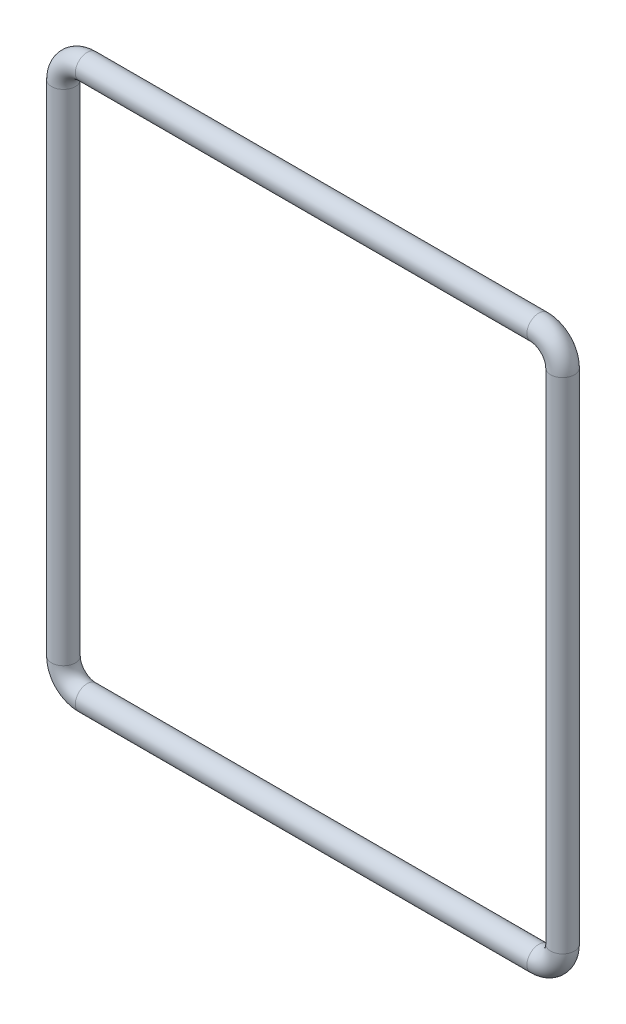
from build123d import *

# Parameters (mm, degrees)
ESQUISSE2_R = 1


with BuildPart() as part:
    # Balayage1: sweep along a path in Esquisse1
    with BuildLine(Plane.XY) as balayage1_path:
        Line((-19, 23), (19, 23))
        ThreePointArc((19, 23), (20.414213562, 22.414213562), (21, 21))
        Line((21, 21), (21, -21))
        ThreePointArc((21, -21), (20.414213562, -22.414213562), (19, -23))
        Line((19, -23), (-19, -23))
        ThreePointArc((-19, -23), (-20.414213562, -22.414213562), (-21, -21))
        Line((-21, -21), (-21, 21))
        ThreePointArc((-21, 21), (-20.414213562, 22.414213562), (-19, 23))
    # Esquisse2 → Balayage1 (sweep)
    with BuildSketch(Plane(origin=(0, 0, 0), x_dir=(1, 0, 0), z_dir=(0, 1, 0))):
        with Locations((21, 0)):
            Circle(ESQUISSE2_R)
    sweep(path=balayage1_path.line)


solid = part.part
